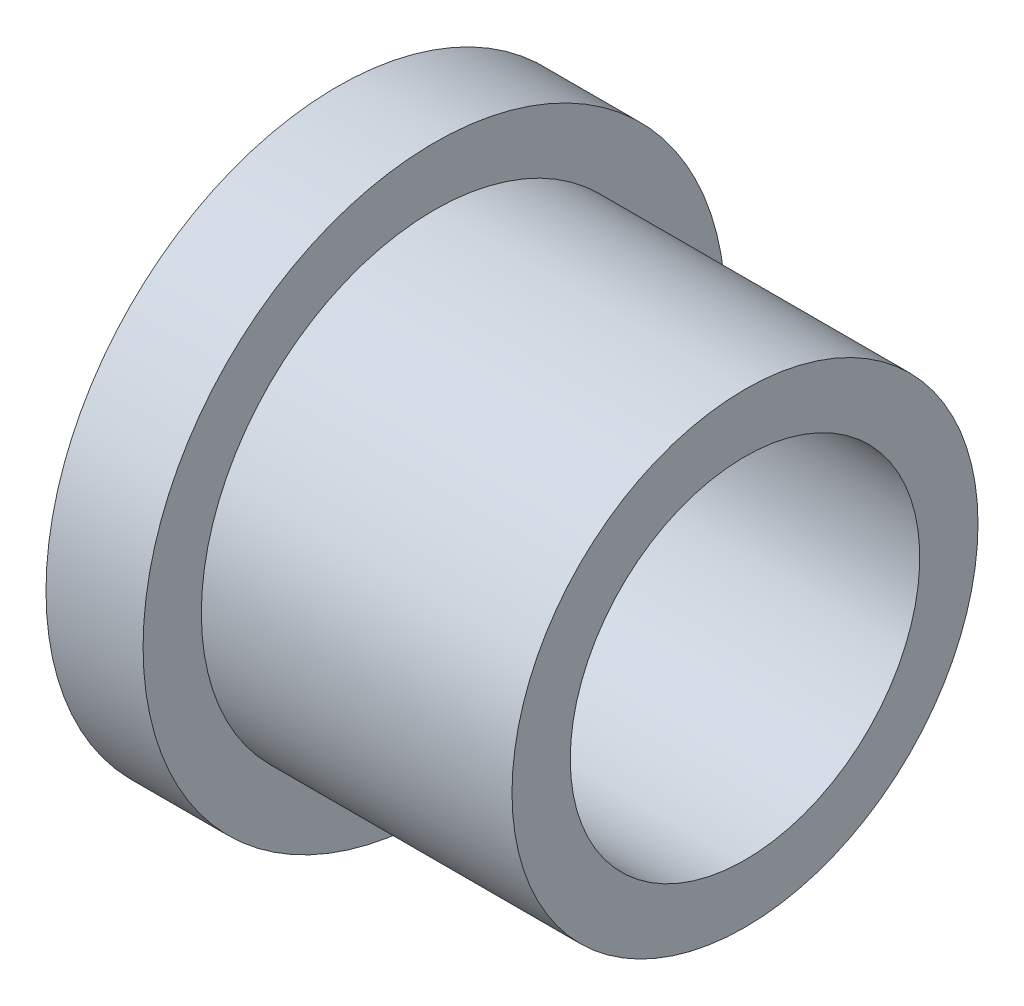
from build123d import *


with BuildPart() as part:
    # Sketch1 → Revolve1 (revolve)
    with BuildSketch(Plane(origin=(0, 0, 0), x_dir=(1, 0, 0), z_dir=(0, 1, 0))):
        Polygon((0, 15), (0, 9), (5, 9), (21, 9), (21, 12), (5, 12), (5, 15), align=None)
    revolve(axis=Axis((0, 0, 0), (1, 0, 0)))


solid = part.part
